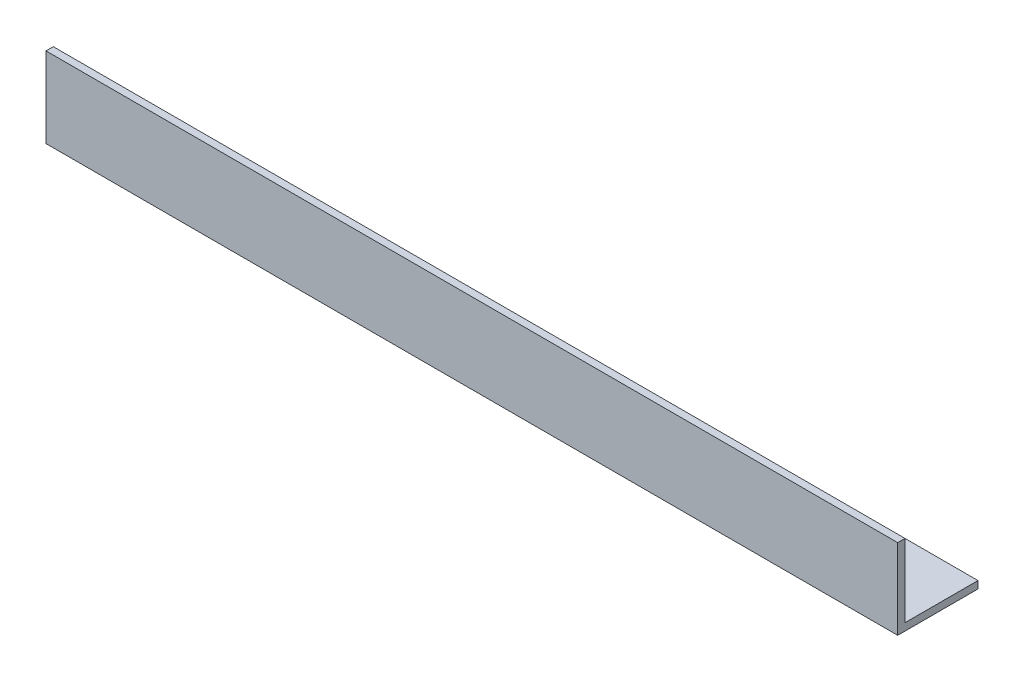
from build123d import *

# Parameters (mm, degrees)
EXTRUDE_1_DEPTH = 350


with BuildPart() as part:
    # Эскиз1 → Вытянуть-Тонкостенный1 (new body)
    with BuildSketch(Plane(origin=(0, 0, 0), x_dir=(0, 0, -1), z_dir=(1, 0, 0))):
        Polygon((0, 33), (0, 0), (33, 0), (33, 3), (3, 3), (3, 33), align=None)
    extrude(amount=EXTRUDE_1_DEPTH)


solid = part.part
